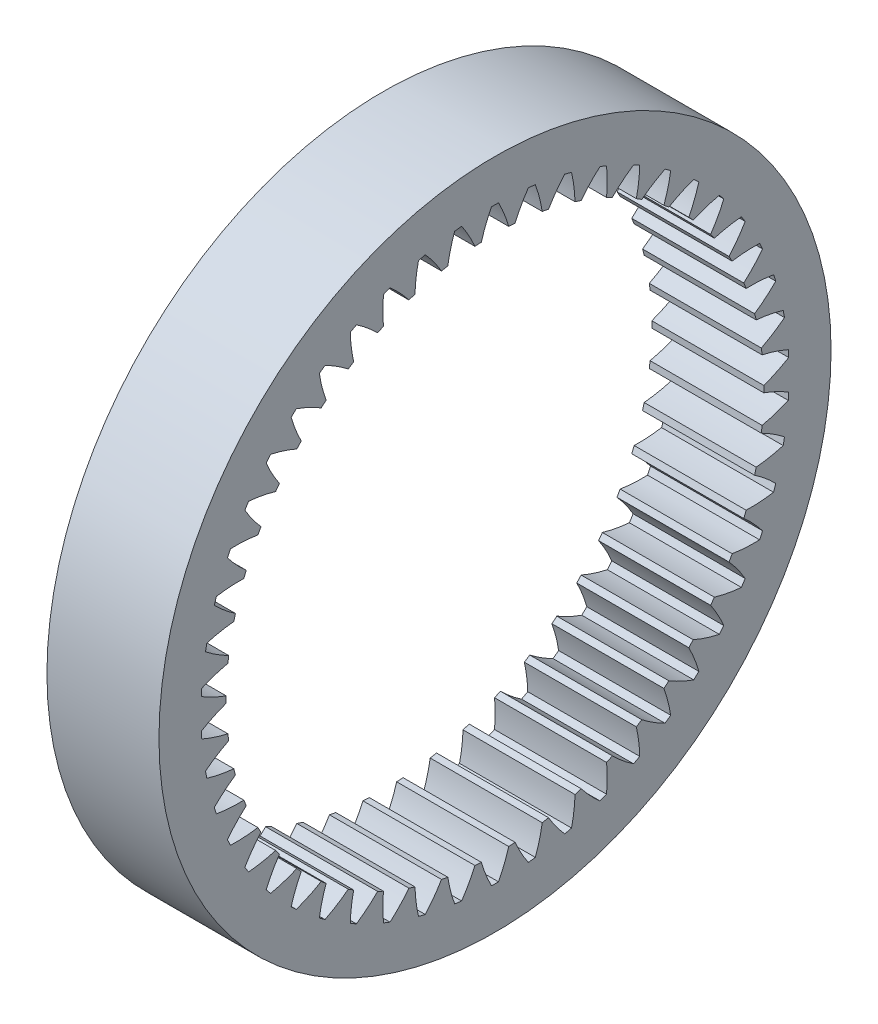
from build123d import *

# Parameters (mm, degrees)
BASPROSKE_W     = 10
BASPROSKE_H     = 6
TOOTHCUT_DEPTH  = 44.588989435
TEETHCUTS_COUNT = 50
TEETHCUTS_ANGLE = 352.8


with BuildPart() as part:
    # BasProSke → Base-Revolve (revolve)
    with BuildSketch(Plane(origin=(0, 0, 0), x_dir=(1, 0, 0), z_dir=(0, 1, 0))):
        with Locations((5, 27)):
            Rectangle(BASPROSKE_W, BASPROSKE_H)
    revolve(axis=Axis((-10, 0, 0), (1, 0, 0)))

    # TooCutSke → ToothCut (cut, through all)
    with BuildSketch(Plane(origin=(0, 0, 0), x_dir=(0, 0, -1), z_dir=(1, 0, 0))):
        with BuildLine():
            ThreePointArc((1.228249008, 23.943116955), (0.8277994, 25.118901547), (0.312635126, 26.249138277))
            ThreePointArc((0.312635126, 26.249138277), (0, 26.251), (-0.312635126, 26.249138277))
            ThreePointArc((-0.312635126, 26.249138277), (-0.8277994, 25.118901547), (-1.228249008, 23.943116955))
            ThreePointArc((-1.228249008, 23.943116955), (0, 23.9746), (1.228249008, 23.943116955))
        make_face()
    toothcut = extrude(amount=TOOTHCUT_DEPTH, mode=Mode.SUBTRACT)

    # TeethCuts: ToothCut ×50 about axis
    teethcuts_axis = Axis((-10, 0, 0), (1, 0, 0))
    for i in range(1, TEETHCUTS_COUNT):
        add(toothcut.rotate(teethcuts_axis, i * TEETHCUTS_ANGLE / (TEETHCUTS_COUNT - 1)), mode=Mode.SUBTRACT)


solid = part.part
